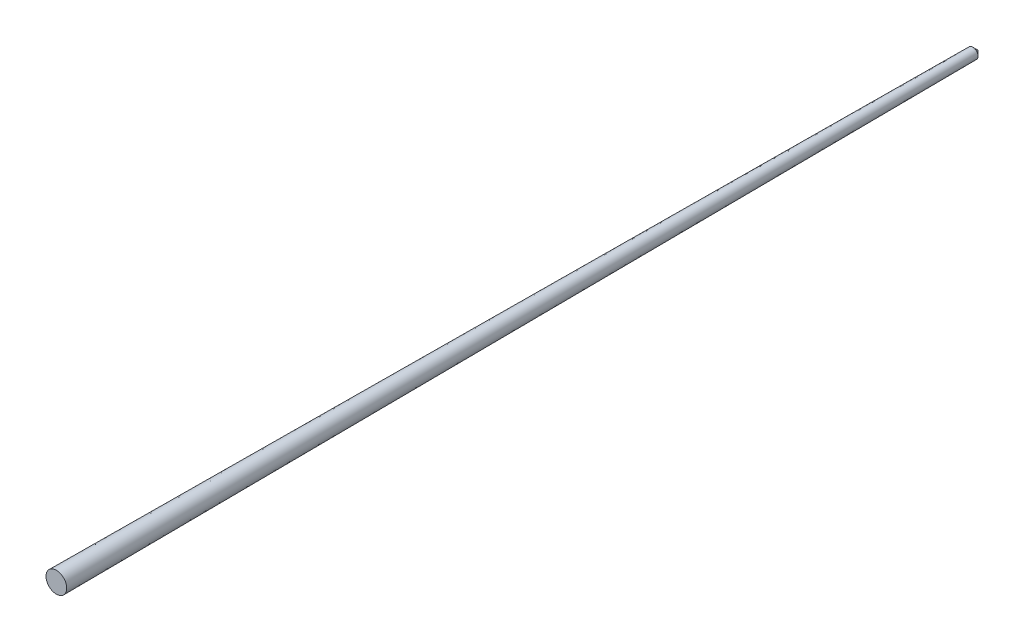
from build123d import *


with BuildPart() as part:
    # Sketch1 → Revolve1 (revolve)
    with BuildSketch(Plane(origin=(0, 0, 0), x_dir=(1, 0, 0), z_dir=(0, 1, 0))):
        Polygon((0, 355.6), (0, 0), (4.02, 0), (2.02, 355.6), (0, 357.62), align=None)
    revolve(axis=Axis((0, 0, -355.6), (0, 0, 1)))


solid = part.part
